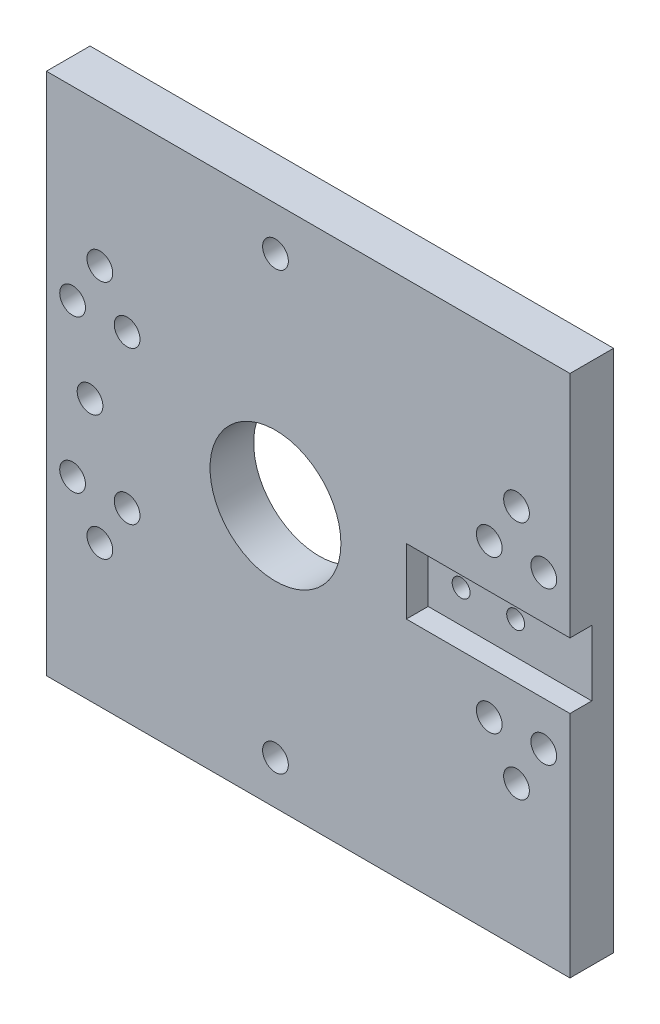
from build123d import *

# Parameters (mm, degrees)
CROQUIS1_R              = 15
CROQUIS1_W              = 37.5
CROQUIS1_H              = 15
CROQUIS1_R_2            = 2.05
SALIENTE_EXTRUIR1_DEPTH = 5
CROQUIS1_4_R            = 15
SALIENTE_EXTRUIR2_DEPTH = 10
CROQUIS2_R              = 2.95
CORTAR_EXTRUIR1_DEPTH   = 91.863909227


with BuildPart() as part:
    # Croquis1 → Saliente-Extruir1 (new body)
    with BuildSketch(Plane.XY):
        Polygon((67.5, 60), (-52.5, 60), (-52.5, -60), (67.5, -60), (67.5, -7.5), (30, -7.5), (30, 7.5), (67.5, 7.5), align=None)
        Circle(CROQUIS1_R, mode=Mode.SUBTRACT)
        with Locations((48.75, 0)):
            Rectangle(CROQUIS1_W, CROQUIS1_H)
        with Locations((37.55, 0)):
            Circle(CROQUIS1_R_2, mode=Mode.SUBTRACT)
        with Locations((50.05, 0)):
            Circle(CROQUIS1_R_2, mode=Mode.SUBTRACT)
    extrude(amount=SALIENTE_EXTRUIR1_DEPTH)

    # Croquis1_4 → Saliente-Extruir2 (add)
    with BuildSketch(Plane.XY):
        Polygon((67.5, 60), (-52.5, 60), (-52.5, -60), (67.5, -60), (67.5, -7.5), (30, -7.5), (30, 7.5), (67.5, 7.5), align=None)
        Circle(CROQUIS1_4_R, mode=Mode.SUBTRACT)
    extrude(amount=SALIENTE_EXTRUIR2_DEPTH)

    # Croquis2 → Cortar-Extruir1 (cut, through all)
    with BuildSketch(Plane.XY.offset(10)):
        with Locations((49, 17.5)):
            Circle(CROQUIS2_R)
        with Locations((55.25, 27.5)):
            Circle(CROQUIS2_R)
        with Locations((61.5, 17.5)):
            Circle(CROQUIS2_R)
        with Locations(Location((61.5, -17.5, 0), (0, 0, 180))):
            Circle(CROQUIS2_R)
        with Locations(Location((55.25, -27.5, 0), (0, 0, 180))):
            Circle(CROQUIS2_R)
        with Locations(Location((49, -17.5, 0), (0, 0, 180))):
            Circle(CROQUIS2_R)
        with Locations((-42.5, 0)):
            Circle(CROQUIS2_R)
        with Locations((0, 50)):
            Circle(CROQUIS2_R)
        with Locations(Location((0, -50, 0), (0, 0, 180))):
            Circle(CROQUIS2_R)
        with Locations((-40.25, -27.5)):
            Circle(CROQUIS2_R)
        with Locations((-46.5, -17.5)):
            Circle(CROQUIS2_R)
        with Locations((-34, -17.5)):
            Circle(CROQUIS2_R)
        with Locations(Location((-34, 17.5, 0), (0, 0, 180))):
            Circle(CROQUIS2_R)
        with Locations(Location((-46.5, 17.5, 0), (0, 0, 180))):
            Circle(CROQUIS2_R)
        with Locations(Location((-40.25, 27.5, 0), (0, 0, 180))):
            Circle(CROQUIS2_R)
    extrude(amount=-CORTAR_EXTRUIR1_DEPTH, mode=Mode.SUBTRACT)


solid = part.part
